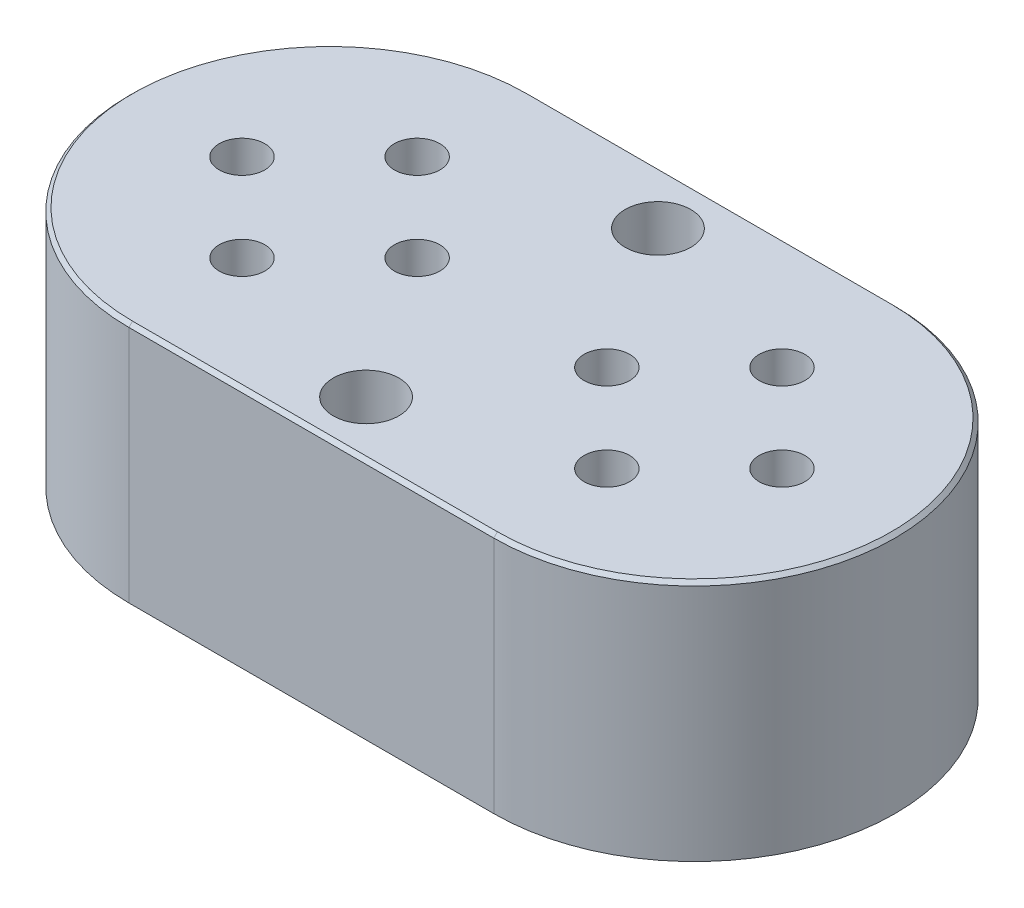
from build123d import *

# Parameters (mm, degrees)
BOSS_EXTRUDE1_DEPTH = 16.8656
CHAMFER1_SIZE       = 0.254
SKETCH3_R           = 1.5875
CUT_EXTRUDE1_DEPTH  = 16.3576
SKETCH4_R           = 2.286
CUT_EXTRUDE2_DEPTH  = 17.8656


with BuildPart() as part:
    # Sketch1 → Boss-Extrude1 (new body)
    with BuildSketch(Plane(origin=(0, 0, 0), x_dir=(1, 0, 0), z_dir=(0, 1, 0))):
        with BuildLine():
            Line((0, 13.97), (25.4, 13.97))
            ThreePointArc((25.4, 13.97), (39.37, 0), (25.4, -13.97))
            Line((25.4, -13.97), (0, -13.97))
            ThreePointArc((0, -13.97), (-13.97, 0), (0, 13.97))
        make_face()
    extrude(amount=BOSS_EXTRUDE1_DEPTH)

    # Chamfer1
    chamfer1_edges = [part.edges().sort_by_distance(p)[0] for p in [
        (39.37, 16.8656, 0),
        (12.7, 16.8656, -13.97),
        (-13.97, 16.8656, 0),
        (12.7, 16.8656, 13.97),
    ]]
    chamfer(chamfer1_edges, length=CHAMFER1_SIZE)

    # Sketch3 → Cut-Extrude1 (cut)
    with BuildSketch(Plane(origin=(0, 16.8656, 0), x_dir=(1, 0, 0), z_dir=(0, 1, 0))):
        with Locations((25.4, 6.096)):
            Circle(SKETCH3_R)
        with Locations((31.496, 0)):
            Circle(SKETCH3_R)
        with Locations((25.4, -6.096)):
            Circle(SKETCH3_R)
        with Locations((19.304, 0)):
            Circle(SKETCH3_R)
        with Locations((-6.096, 0)):
            Circle(SKETCH3_R)
        with Locations((6.096, 0)):
            Circle(SKETCH3_R)
        with Locations((0, -6.096)):
            Circle(SKETCH3_R)
        with Locations((0, 6.096)):
            Circle(SKETCH3_R)
    extrude(amount=-CUT_EXTRUDE1_DEPTH, mode=Mode.SUBTRACT)

    # Sketch4 → Cut-Extrude2 (cut, through all)
    with BuildSketch(Plane(origin=(0, 16.8656, 0), x_dir=(1, 0, 0), z_dir=(0, 1, 0))):
        with Locations((12.7, 10.16)):
            Circle(SKETCH4_R)
        with Locations((12.7, -10.16)):
            Circle(SKETCH4_R)
    extrude(amount=-CUT_EXTRUDE2_DEPTH, mode=Mode.SUBTRACT)


solid = part.part
